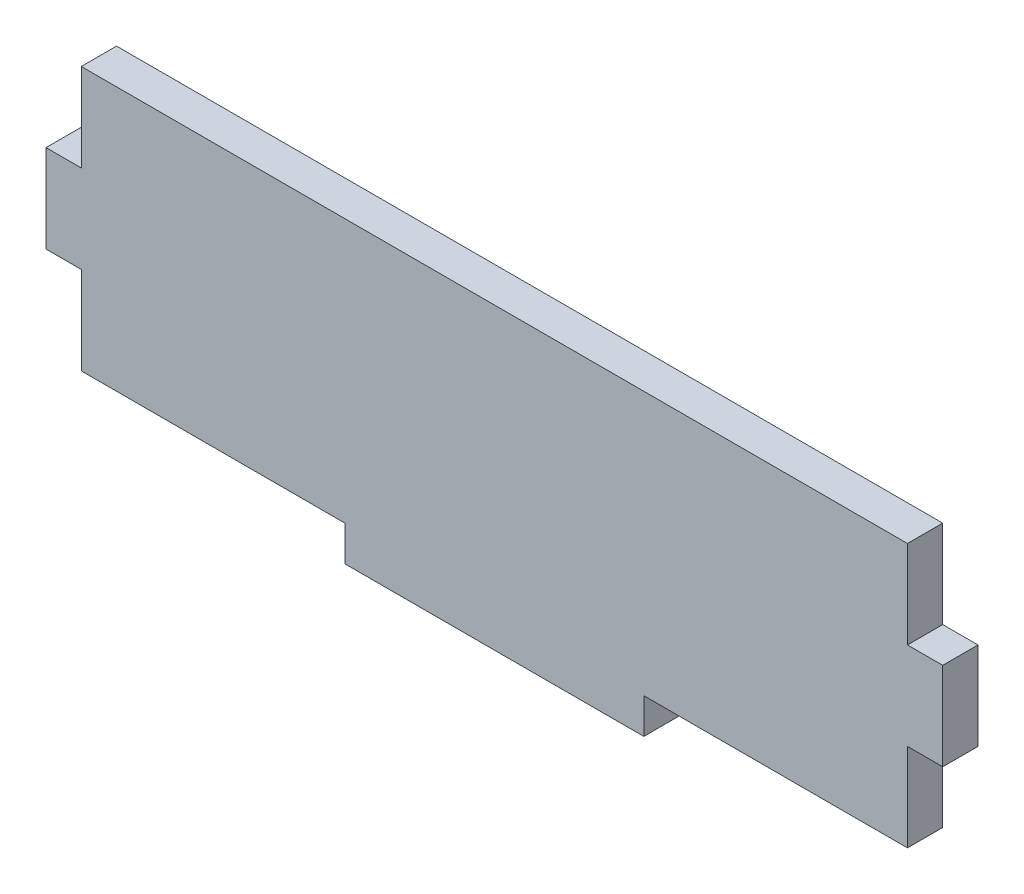
from build123d import *

# Parameters (mm, degrees)
BOSS_EXTRUDE1_DEPTH = 2.9972


with BuildPart() as part:
    # Sketch1 → Boss-Extrude1 (new body)
    with BuildSketch(Plane.XY):
        Polygon((21.812958309, 7.872019093), (47.212958309, 7.872019093), (47.212958309, 10.869219093), (69.615758309, 10.869219093), (69.615758309, 18.336819093), (72.612958309, 18.336819093), (72.612958309, 25.804419093), (69.615758309, 25.804419093), (69.615758309, 33.272019093), (-0.589841691, 33.272019093), (-0.589841691, 25.804419093), (-3.587041691, 25.804419093), (-3.587041691, 18.336819093), (-0.589841691, 18.336819093), (-0.589841691, 10.869219093), (21.812958309, 10.869219093), align=None)
    extrude(amount=BOSS_EXTRUDE1_DEPTH)


solid = part.part
